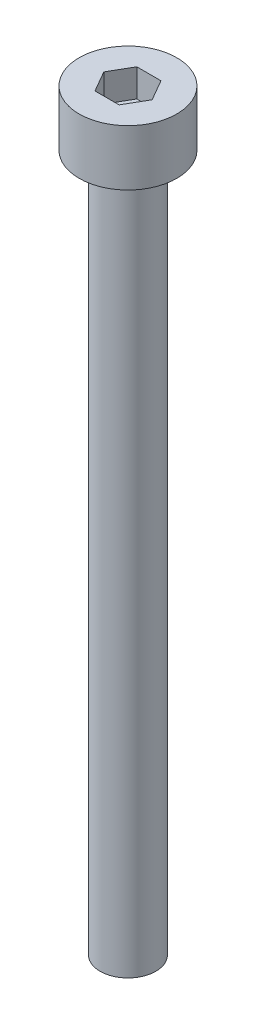
from build123d import *

# Parameters (mm, degrees)
SKETCH_1_R            = 3.5
EXTRUDE_246_DEPTH     = 4
CUT_EXTRUDE_376_DEPTH = 2
SKETCH_3_R            = 2
EXTRUDE_477_DEPTH     = 50


with BuildPart() as part:
    # 草图1 → Extrude 246 (new body)
    with BuildSketch(Plane(origin=(0, 0, 0), x_dir=(1, 0, 0), z_dir=(0, 1, 0))):
        Circle(SKETCH_1_R)
    extrude(amount=EXTRUDE_246_DEPTH)

    # 草图2 → Cut-Extrude 376 (cut)
    with BuildSketch(Plane(origin=(0, 4, 0), x_dir=(1, 0, 0), z_dir=(0, 1, 0))):
        Polygon((1.732050808, 0), (0.866025404, 1.5), (-0.866025404, 1.5), (-1.732050808, 0), (-0.866025404, -1.5), (0.866025404, -1.5), align=None)
    extrude(amount=-CUT_EXTRUDE_376_DEPTH, mode=Mode.SUBTRACT)

    # 草图3 → Extrude 477 (add)
    with BuildSketch(Plane.XZ):
        Circle(SKETCH_3_R)
    extrude(amount=EXTRUDE_477_DEPTH)


solid = part.part
